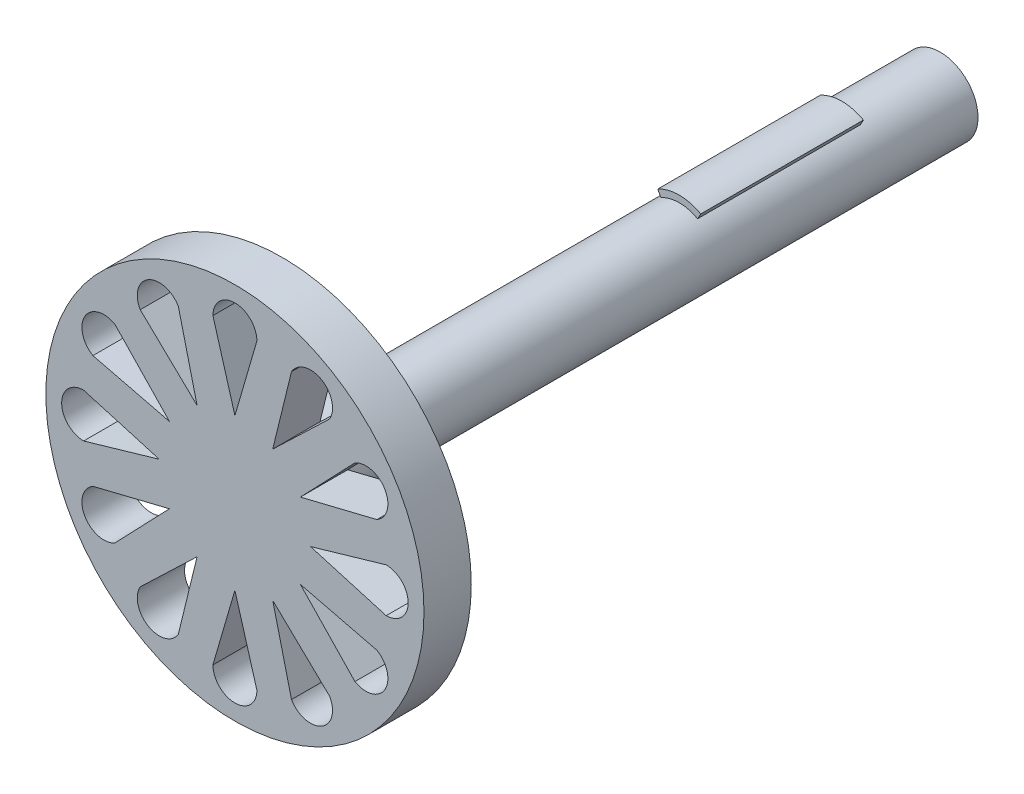
from build123d import *

# Parameters (mm, degrees)
SKETCH3_R           = 2
BOSS_EXTRUDE1_DEPTH = 5.2
SKETCH4_R           = 2
BOSS_EXTRUDE2_DEPTH = 8.6
SKETCH5_R           = 2
BOSS_EXTRUDE3_DEPTH = 15
SKETCH7_R           = 2
BOSS_EXTRUDE4_DEPTH = 6
SKETCH8_R           = 10
BOSS_EXTRUDE5_DEPTH = 2.5
CUT_EXTRUDE1_DEPTH  = 12


with BuildPart() as part:
    # Sketch3 → Boss-Extrude1 (new body)
    with BuildSketch(Plane.XY):
        Circle(SKETCH3_R)
    extrude(amount=BOSS_EXTRUDE1_DEPTH)

    # Sketch4 → Boss-Extrude2 (add)
    with BuildSketch(Plane.XY.offset(5.2)):
        with Locations(Location((0, 0, 0), (0, 0, 119))):
            Circle(SKETCH4_R)
        with BuildLine():
            Line((0, 0), (1.139302608, 2.055356312))
            ThreePointArc((1.139302608, 2.055356312), (0, 2.35), (-1.139302608, 2.055356312))
            Line((-1.139302608, 2.055356312), (0, 0))
        make_face()
        with BuildLine():
            Line((0.96961924, 1.749239414), (0, 0))
            Line((0, 0), (-0.96961924, 1.749239414))
            ThreePointArc((-0.96961924, 1.749239414), (-1.015076726, -1.723258321), (2, 0))
            ThreePointArc((2, 0), (1.723258321, 1.015076726), (0.96961924, 1.749239414))
        make_face()
    extrude(amount=BOSS_EXTRUDE2_DEPTH)

    # Sketch5 → Boss-Extrude3 (add)
    with BuildSketch(Plane.XY.offset(13.8)):
        Circle(SKETCH5_R)
    extrude(amount=BOSS_EXTRUDE3_DEPTH)

    # Sketch7 → Boss-Extrude4 (add)
    with BuildSketch(Plane.XY.offset(28.8)):
        Circle(SKETCH7_R)
    extrude(amount=BOSS_EXTRUDE4_DEPTH)

    # Sketch8 → Boss-Extrude5 (add)
    with BuildSketch(Plane.XY.offset(34.8)):
        Circle(SKETCH8_R)
    extrude(amount=BOSS_EXTRUDE5_DEPTH)

    # Sketch9 → Cut-Extrude1 (cut)
    with BuildSketch(Plane.XY.offset(37.3)):
        with BuildLine():
            Line((7.509902395, -2.992467491), (3.464101615, -2))
            Line((3.464101615, -2), (6.346504065, -5.007532509))
            ThreePointArc((6.346504065, -5.007532509), (7.935735739, -4.581699165), (7.509902395, -2.992467491))
        make_face()
        with BuildLine():
            Line((-6.346504065, 5.007532509), (-3.464101615, 2))
            Line((-3.464101615, 2), (-7.509902395, 2.992467491))
            ThreePointArc((-7.509902395, 2.992467491), (-7.935735739, 4.581699165), (-6.346504065, 5.007532509))
        make_face()
        with BuildLine():
            Line((-7.509902395, -2.992467491), (-3.464101615, -2))
            Line((-3.464101615, -2), (-6.346504065, -5.007532509))
            ThreePointArc((-6.346504065, -5.007532509), (-7.935735739, -4.581699165), (-7.509902395, -2.992467491))
        make_face()
        with BuildLine():
            Line((6.346504065, 5.007532509), (3.464101615, 2))
            Line((3.464101615, 2), (7.509902395, 2.992467491))
            ThreePointArc((7.509902395, 2.992467491), (7.935735739, 4.581699165), (6.346504065, 5.007532509))
        make_face()
        with BuildLine():
            Line((-1.16339833, -8), (0, -4))
            Line((0, -4), (1.16339833, -8))
            ThreePointArc((1.16339833, -8), (0, -9.16339833), (-1.16339833, -8))
        make_face()
        with BuildLine():
            Line((1.16339833, 8), (0, 4))
            Line((0, 4), (-1.16339833, 8))
            ThreePointArc((-1.16339833, 8), (0, 9.16339833), (1.16339833, 8))
        make_face()
        with BuildLine():
            Line((-8, 1.16339833), (-4, 0))
            Line((-4, 0), (-8, -1.16339833))
            ThreePointArc((-8, -1.16339833), (-9.16339833, 0), (-8, 1.16339833))
        make_face()
        with BuildLine():
            Line((8, -1.16339833), (4, 0))
            Line((4, 0), (8, 1.16339833))
            ThreePointArc((8, 1.16339833), (9.16339833, 0), (8, -1.16339833))
        make_face()
        with BuildLine():
            Line((-2.992467491, 7.509902395), (-2, 3.464101615))
            Line((-2, 3.464101615), (-5.007532509, 6.346504065))
            ThreePointArc((-5.007532509, 6.346504065), (-4.581699165, 7.935735739), (-2.992467491, 7.509902395))
        make_face()
        with BuildLine():
            Line((5.007532509, -6.346504065), (2, -3.464101615))
            Line((2, -3.464101615), (2.992467491, -7.509902395))
            ThreePointArc((2.992467491, -7.509902395), (4.581699165, -7.935735739), (5.007532509, -6.346504065))
        make_face()
        with BuildLine():
            Line((2.992467491, 7.509902395), (2, 3.464101615))
            Line((2, 3.464101615), (5.007532509, 6.346504065))
            ThreePointArc((5.007532509, 6.346504065), (4.581699165, 7.935735739), (2.992467491, 7.509902395))
        make_face()
        with BuildLine():
            Line((-5.007532509, -6.346504065), (-2, -3.464101615))
            Line((-2, -3.464101615), (-2.992467491, -7.509902395))
            ThreePointArc((-2.992467491, -7.509902395), (-4.581699165, -7.935735739), (-5.007532509, -6.346504065))
        make_face()
    extrude(amount=-CUT_EXTRUDE1_DEPTH, mode=Mode.SUBTRACT)


solid = part.part
